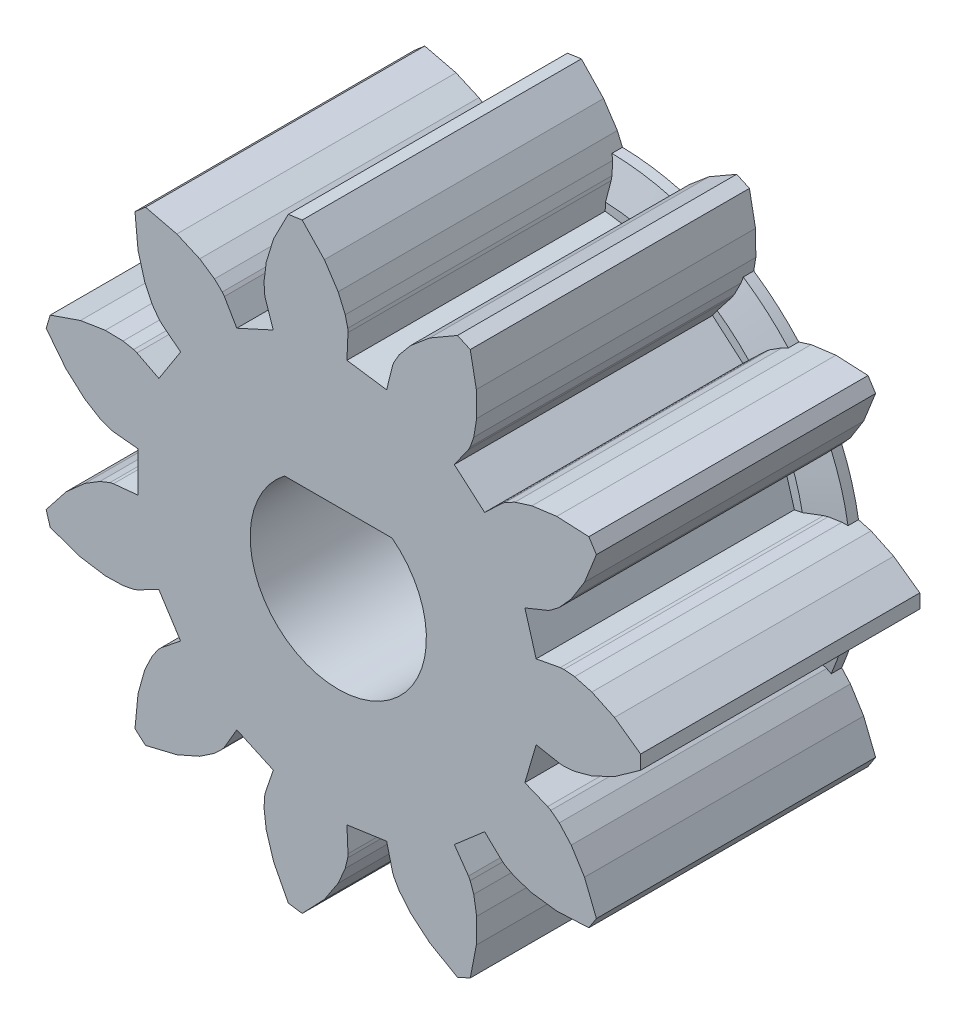
from build123d import *

# Parameters (mm, degrees)
BOSS_EXTRUDE1_DEPTH   = 8
CUT_EXTRUDE1_DEPTH    = 9
CHAMFER1_SIZE         = 1
CHAMFER1_SIZE2        = 0.577350269
CHAMFER1_PART_2_SIZE  = 1
CHAMFER1_PART_2_SIZE2 = 0.577350269


with BuildPart() as part:
    # Model → Boss-Extrude1 (new body)
    with BuildSketch(Plane.XY):
        Polygon((-8.37, -2.248), (-7.801, -1.524), (-7.265, -1.048), (-6.829, -0.78), (-6.543, -0.667), (-6.442, -0.645), (-5.741, -0.575), (-5.741, 0.575), (-6.442, 0.645), (-6.543, 0.667), (-6.829, 0.78), (-7.265, 1.048), (-7.801, 1.524), (-8.37, 2.248), (-8.256, 2.634), (-7.386, 2.935), (-6.678, 3.046), (-6.167, 3.035), (-5.865, 2.976), (-5.768, 2.94), (-5.14, 2.62), (-4.518, 3.587), (-5.071, 4.026), (-5.143, 4.099), (-5.323, 4.348), (-5.545, 4.81), (-5.738, 5.5), (-5.826, 6.416), (-5.522, 6.679), (-4.627, 6.462), (-3.971, 6.173), (-3.547, 5.887), (-3.325, 5.674), (-3.263, 5.592), (-2.908, 4.983), (-1.862, 5.461), (-2.089, 6.128), (-2.111, 6.229), (-2.127, 6.536), (-2.064, 7.044), (-1.854, 7.729), (-1.432, 8.547), (-1.034, 8.604), (-0.399, 7.938), (-0.004, 7.34), (0.199, 6.87), (0.271, 6.571), (0.278, 6.468), (0.248, 5.764), (1.386, 5.601), (1.555, 6.285), (1.592, 6.381), (1.744, 6.648), (2.071, 7.042), (2.619, 7.504), (3.416, 7.965), (3.782, 7.798), (3.956, 6.893), (3.965, 6.177), (3.882, 5.672), (3.78, 5.382), (3.731, 5.291), (3.325, 4.715), (4.194, 3.962), (4.706, 4.446), (4.789, 4.508), (5.062, 4.65), (5.55, 4.804), (6.26, 4.897), (7.18, 4.853), (7.397, 4.515), (7.055, 3.66), (6.675, 3.053), (6.332, 2.673), (6.09, 2.484), (6, 2.434), (5.347, 2.169), (5.67, 1.066), (6.363, 1.196), (6.466, 1.203), (6.772, 1.175), (7.266, 1.041), (7.914, 0.735), (8.664, 0.201), (8.664, -0.201), (7.914, -0.735), (7.266, -1.041), (6.772, -1.175), (6.466, -1.203), (6.363, -1.196), (5.67, -1.066), (5.346, -2.169), (6, -2.434), (6.09, -2.484), (6.332, -2.673), (6.675, -3.053), (7.055, -3.66), (7.397, -4.515), (7.18, -4.853), (6.26, -4.897), (5.55, -4.804), (5.062, -4.65), (4.789, -4.508), (4.706, -4.446), (4.194, -3.962), (3.325, -4.715), (3.731, -5.291), (3.78, -5.382), (3.882, -5.672), (3.965, -6.177), (3.956, -6.893), (3.782, -7.798), (3.416, -7.965), (2.619, -7.504), (2.071, -7.042), (1.744, -6.648), (1.592, -6.381), (1.555, -6.285), (1.386, -5.601), (0.248, -5.764), (0.278, -6.468), (0.271, -6.571), (0.199, -6.87), (-0.004, -7.34), (-0.399, -7.938), (-1.034, -8.604), (-1.432, -8.547), (-1.854, -7.729), (-2.064, -7.044), (-2.127, -6.536), (-2.111, -6.229), (-2.089, -6.128), (-1.862, -5.461), (-2.908, -4.983), (-3.263, -5.592), (-3.325, -5.674), (-3.547, -5.887), (-3.971, -6.173), (-4.627, -6.462), (-5.522, -6.679), (-5.826, -6.416), (-5.738, -5.5), (-5.545, -4.81), (-5.323, -4.348), (-5.143, -4.099), (-5.071, -4.026), (-4.519, -3.587), (-5.141, -2.62), (-5.768, -2.94), (-5.865, -2.976), (-6.167, -3.035), (-6.678, -3.046), (-7.386, -2.935), (-8.256, -2.634), align=None)
    extrude(amount=BOSS_EXTRUDE1_DEPTH)

    # Sketch2 → Cut-Extrude1 (cut, through all)
    with BuildSketch(Plane.XY.offset(8)):
        with BuildLine():
            Line((-1.541306264, 2), (1.541306264, 2))
            ThreePointArc((1.541306264, 2), (0, -2.525), (-1.541306264, 2))
        make_face()
    extrude(amount=-CUT_EXTRUDE1_DEPTH, mode=Mode.SUBTRACT)

    # Sketch3 → Revolve1 (revolve)
    with BuildSketch(Plane(origin=(0, 0, 0), x_dir=(1, 0, 0), z_dir=(0, 1, 0))):
        Polygon((3.2, 0), (3.2, -0.6), (6, -0.6), (7, -0.3), (7, 0), align=None)
    revolve(axis=Axis((0, 0, 0), (0, 0, 1)))

    # Chamfer1
    chamfer1_edges = [part.edges().sort_by_distance(p)[0] for p in [
        (0, -2.525, 0),
    ]]
    chamfer1_side = [part.faces().sort_by_distance(p)[0] for p in [
        (0, -2.525, 4),
    ]]
    chamfer(chamfer1_edges, length=CHAMFER1_SIZE, length2=CHAMFER1_SIZE2, reference=chamfer1_side[0])

    # Chamfer1 part 2
    chamfer1_part_2_edges = [part.edges().sort_by_distance(p)[0] for p in [
        (0, 2, 0),
    ]]
    chamfer1_part_2_side = [part.faces().sort_by_distance(p)[0] for p in [
        (0, 2, 4),
    ]]
    chamfer(chamfer1_part_2_edges, length=CHAMFER1_PART_2_SIZE, length2=CHAMFER1_PART_2_SIZE2, reference=chamfer1_part_2_side[0])


solid = part.part
